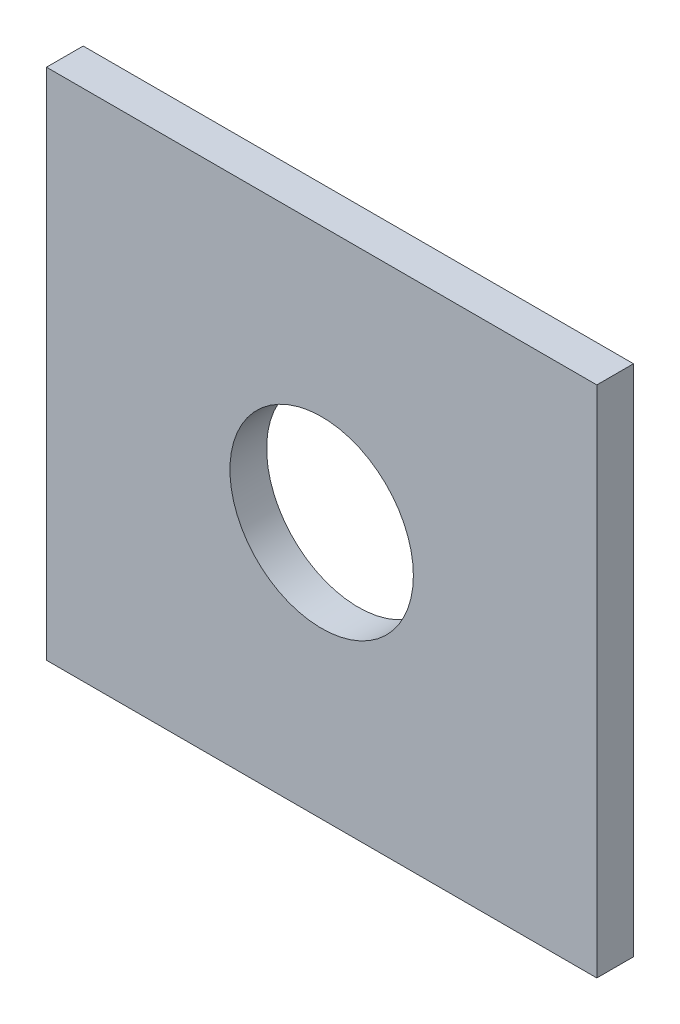
from build123d import *

# Parameters (mm, degrees)
SKETCH1_W           = 150
SKETCH1_H           = 140
SKETCH1_R           = 25
BOSS_EXTRUDE1_DEPTH = 10


with BuildPart() as part:
    # Sketch1 → Boss-Extrude1 (new body)
    with BuildSketch(Plane.XY):
        Rectangle(SKETCH1_W, SKETCH1_H)
        Circle(SKETCH1_R, mode=Mode.SUBTRACT)
    extrude(amount=BOSS_EXTRUDE1_DEPTH)


solid = part.part
